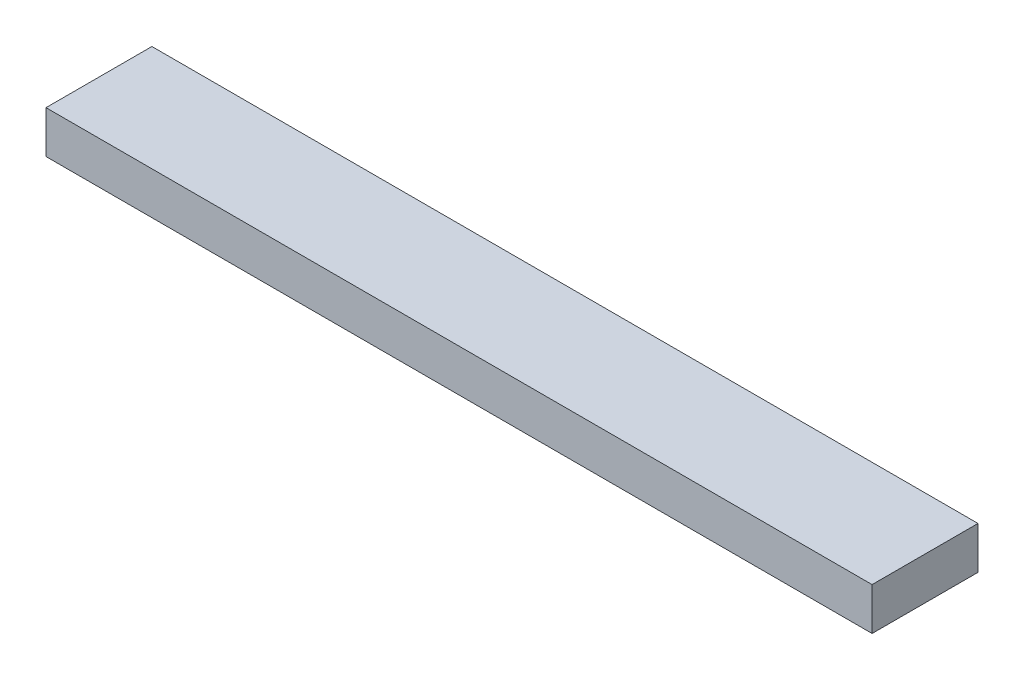
from build123d import *

# Parameters (mm, degrees)
SKETCH1_W           = 127
SKETCH1_H           = 50.8
BOSS_EXTRUDE1_DEPTH = 990.6


with BuildPart() as part:
    # Sketch1 → Boss-Extrude1 (new body)
    with BuildSketch(Plane(origin=(0, 0, 0), x_dir=(0, 0, -1), z_dir=(1, 0, 0))):
        with Locations((63.5, 25.4)):
            Rectangle(SKETCH1_W, SKETCH1_H)
    extrude(amount=BOSS_EXTRUDE1_DEPTH)


solid = part.part
